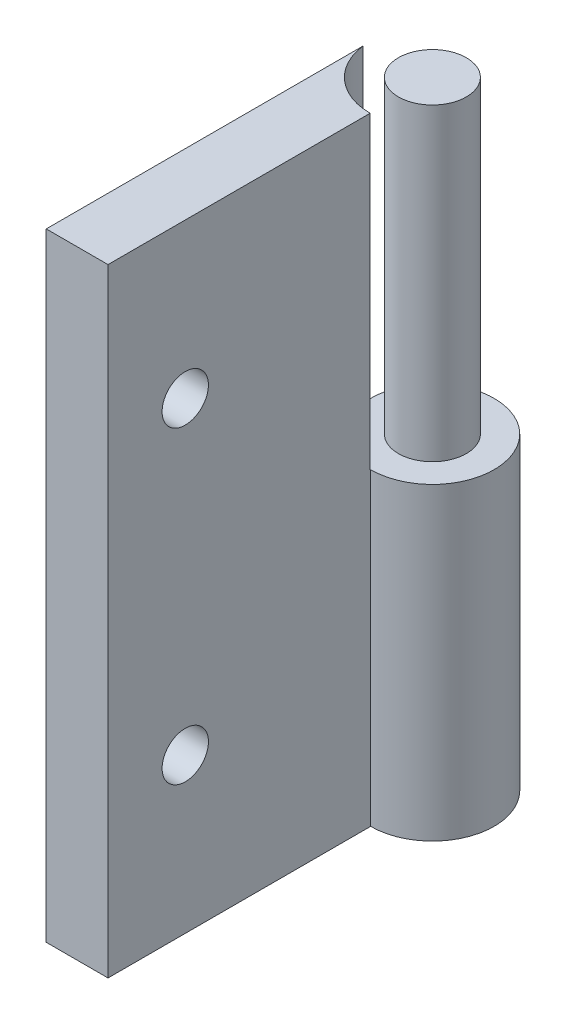
from build123d import *

# Parameters (mm, degrees)
SKETCH1_W           = 4
SKETCH1_H           = 40
EXTRUDE_THIN2_DEPTH = 21
SKETCH4_R           = 4
SKETCH15_R          = 4.03
SKETCH15_R_2        = 2.2
CUT_EXTRUDE14_DEPTH = 20
SKETCH13_R          = 1.5
CUT_EXTRUDE10_DEPTH = 46.354161882


with BuildPart() as part:
    # Sketch1 → Extrude-Thin2 (new body)
    with BuildSketch(Plane.XY):
        with Locations((2, 20)):
            Rectangle(SKETCH1_W, SKETCH1_H)
    extrude(amount=EXTRUDE_THIN2_DEPTH)

    # Sweep3: sweep along a curve in space
    with BuildLine() as sweep3_path:
        Line((4, 0, 0), (4, 40, 0))
    # Sketch4 → Sweep3 (sweep)
    with BuildSketch(Plane(origin=(0, 40, 0), x_dir=(1, 0, 0), z_dir=(0, 1, 0))):
        with Locations((4, 0)):
            Circle(SKETCH4_R)
    sweep(path=sweep3_path.line)

    # Sketch15 → Cut-Extrude14 (cut)
    with BuildSketch(Plane(origin=(0, 40, 0), x_dir=(1, 0, 0), z_dir=(0, 1, 0))):
        with Locations((4, 0)):
            Circle(SKETCH15_R)
        with Locations(Location((4, 0, 0), (0, 0, 270))):
            Circle(SKETCH15_R_2, mode=Mode.SUBTRACT)
    extrude(amount=-CUT_EXTRUDE14_DEPTH, mode=Mode.SUBTRACT)

    # Sketch13 → Cut-Extrude10 (cut, through all)
    with BuildSketch(Plane(origin=(4, 0, 0), x_dir=(0, 0, -1), z_dir=(1, 0, 0))):
        with Locations((-16, 30)):
            Circle(SKETCH13_R)
        with Locations((-16, 10)):
            Circle(SKETCH13_R)
    extrude(amount=-CUT_EXTRUDE10_DEPTH, mode=Mode.SUBTRACT)


solid = part.part
